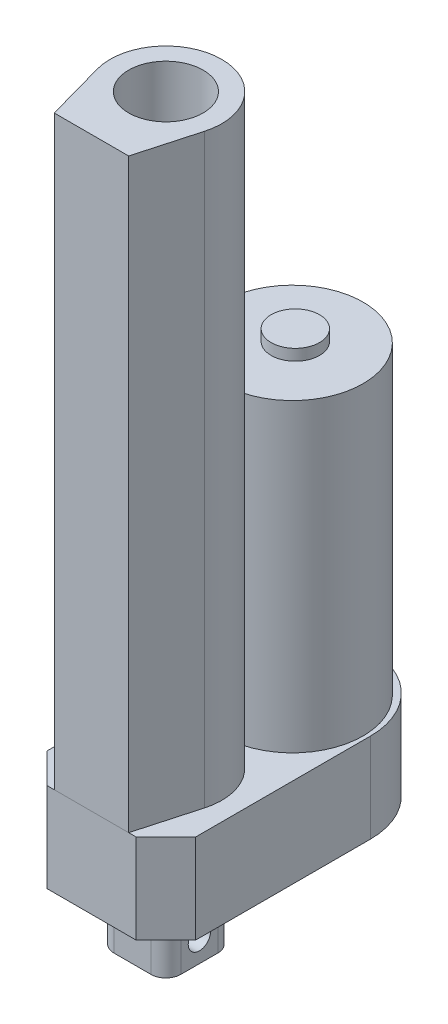
from build123d import *

# Parameters (mm, degrees)
EXTRUDE_1_DEPTH          = 24
EXTRUDE_2_DEPTH          = 17
SKETCH_3_R               = 3
CUT_EXTRUDE_1_DEPTH      = 12
CUT_EXTRUDE_1_DEPTH_BACK = 30
SKETCH_4_R               = 19
EXTRUDE_3_DEPTH          = 82
SKETCH_5_R               = 6.5
EXTRUDE_4_DEPTH          = 3
SKETCH_6_R               = 10
EXTRUDE_7_DEPTH          = 157.5


with BuildPart() as part:
    # 草图1 → 凸台-拉伸1 (new body)
    with BuildSketch(Plane(origin=(0, 0, 0), x_dir=(1, 0, 0), z_dir=(0, 1, 0))):
        with BuildLine():
            Line((0, 8), (8, 0))
            Line((8, 0), (32, 0))
            Line((32, 0), (40, 8))
            Line((40, 8), (40, 55))
            ThreePointArc((40, 55), (20, 75), (0, 55))
            Line((0, 55), (0, 8))
        make_face()
    extrude(amount=EXTRUDE_1_DEPTH)

    # 草图2 → 凸台-拉伸2 (add)
    with BuildSketch(Plane.XZ):
        with BuildLine():
            Line((15, -11), (25, -11))
            ThreePointArc((25, -11), (27.828427125, -12.171572875), (29, -15))
            Line((29, -15), (29, -25))
            ThreePointArc((29, -25), (27.828427125, -27.828427125), (25, -29))
            Line((25, -29), (15, -29))
            ThreePointArc((15, -29), (12.171572875, -27.828427125), (11, -25))
            Line((11, -25), (11, -15))
            ThreePointArc((11, -15), (12.171572875, -12.171572875), (15, -11))
        make_face()
    extrude(amount=EXTRUDE_2_DEPTH)

    # 草图3 → 切除-拉伸1 (cut, two sides)
    with BuildSketch(Plane(origin=(29, 0, 0), x_dir=(0, 0, -1), z_dir=(1, 0, 0))) as cut_extrude_1_sk:
        with Locations((20, -11)):
            Circle(SKETCH_3_R)
    extrude(amount=CUT_EXTRUDE_1_DEPTH, mode=Mode.SUBTRACT)
    extrude(cut_extrude_1_sk.sketch, amount=-CUT_EXTRUDE_1_DEPTH_BACK, mode=Mode.SUBTRACT)

    # 草图4 → 凸台-拉伸3 (add)
    with BuildSketch(Plane(origin=(0, 24, 0), x_dir=(1, 0, 0), z_dir=(0, 1, 0))):
        with Locations((20, 54)):
            Circle(SKETCH_4_R)
    extrude(amount=EXTRUDE_3_DEPTH)

    # 草图5 → 凸台-拉伸4 (add)
    with BuildSketch(Plane(origin=(0, 106, 0), x_dir=(1, 0, 0), z_dir=(0, 1, 0))):
        with Locations((20.076647574, 54.707380465)):
            Circle(SKETCH_5_R)
    extrude(amount=EXTRUDE_4_DEPTH)


with BuildPart() as body_2:
    # 草图6 → 凸台-拉伸7 (new body)
    with BuildSketch(Plane(origin=(0, 24, 0), x_dir=(1, 0, 0), z_dir=(0, 1, 0))):
        with BuildLine():
            Line((10, 0), (5.550125629, 15.974937186))
            ThreePointArc((5.550125629, 15.974937186), (20, 35), (34.449874371, 15.974937186))
            Line((34.449874371, 15.974937186), (30, 0))
            Line((30, 0), (10, 0))
        make_face()
        with Locations((20, 20)):
            Circle(SKETCH_6_R, mode=Mode.SUBTRACT)
    extrude(amount=EXTRUDE_7_DEPTH)


solid = Compound([part.part, body_2.part])
